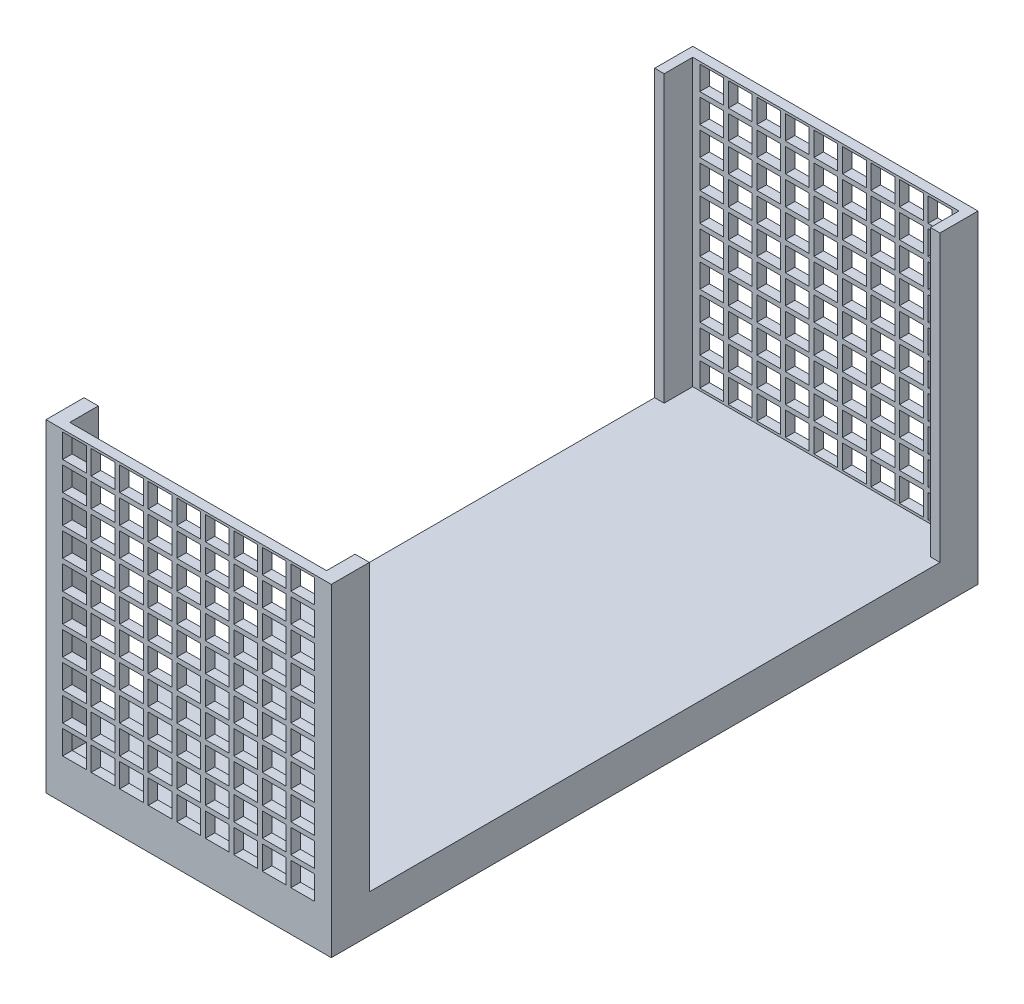
from build123d import *

# Parameters (mm, degrees)
SKETCH1_W            = 15
SKETCH1_H            = 17
BOSS_EXTRUDE1_DEPTH  = 34
CUT_EXTRUDE1_REACH   = 17
SKETCH2_W            = 30
SKETCH2_H            = 15
CUT_EXTRUDE4_START   = -2
SKETCH5_W            = 14
SKETCH5_H            = 15
CUT_EXTRUDE4_DEPTH   = 1.5
CUT_EXTRUDE2_START   = -2
SKETCH3_W            = 13.5
SKETCH3_H            = 15
CUT_EXTRUDE2_DEPTH   = 1.5
CUT_EXTRUDE5_START   = -0.5
SKETCH6_W            = 1.25
SKETCH6_H            = 1.25
CUT_EXTRUDE5_DEPTH   = 35
LPATTERN1_COUNT      = 9
LPATTERN1_PITCH      = 1.5
LPATTERN1_COUNT_DIR2 = 10
LPATTERN1_PITCH_DIR2 = 1.5


with BuildPart() as part:
    # Sketch1 → Boss-Extrude1 (new body)
    with BuildSketch(Plane.XY):
        Rectangle(SKETCH1_W, SKETCH1_H)
    extrude(amount=BOSS_EXTRUDE1_DEPTH)

    # Sketch2 → Cut-Extrude1 (cut, up to next)
    with BuildSketch(Plane(origin=(7.5, 0, 0), x_dir=(0, 0, -1), z_dir=(1, 0, 0)), mode=Mode.PRIVATE) as cut_extrude1_sk1:
        with Locations((-17, 1)):
            Rectangle(SKETCH2_W, SKETCH2_H)
    cut_extrude1_tool1 = extrude(cut_extrude1_sk1.sketch, amount=-CUT_EXTRUDE1_REACH, mode=Mode.PRIVATE) & part.part
    add(cut_extrude1_tool1.solids().sort_by_distance((7.5, 1, 17))[0], mode=Mode.SUBTRACT)

    # Sketch5 → Cut-Extrude4 (cut)
    with BuildSketch(Plane(origin=(0, 0, 0), x_dir=(-1, 0, 0), z_dir=(0, 0, -1)).offset(CUT_EXTRUDE4_START)):
        with Locations((0, 1)):
            Rectangle(SKETCH5_W, SKETCH5_H)
    extrude(amount=CUT_EXTRUDE4_DEPTH, mode=Mode.SUBTRACT)

    # Sketch3 → Cut-Extrude2 (cut)
    with BuildSketch(Plane.XY.offset(34).offset(CUT_EXTRUDE2_START)):
        with Locations((0, 1)):
            Rectangle(SKETCH3_W, SKETCH3_H)
    extrude(amount=CUT_EXTRUDE2_DEPTH, mode=Mode.SUBTRACT)

    # Sketch6 → Cut-Extrude5 (cut, through all)
    with BuildSketch(Plane(origin=(0, 0, 33.5), x_dir=(-1, 0, 0), z_dir=(0, 0, -1)).offset(CUT_EXTRUDE5_START)):
        with Locations((-6, 7.75)):
            Rectangle(SKETCH6_W, SKETCH6_H)
    cut_extrude5 = extrude(amount=CUT_EXTRUDE5_DEPTH, mode=Mode.SUBTRACT)

    # LPattern1: Cut-Extrude5 9 × 10
    with Locations(*[(-i * LPATTERN1_PITCH, -j * LPATTERN1_PITCH_DIR2, 0) for i in range(LPATTERN1_COUNT) for j in range(LPATTERN1_COUNT_DIR2) if (i, j) != (0, 0)]):
        add(cut_extrude5, mode=Mode.SUBTRACT)


solid = part.part
